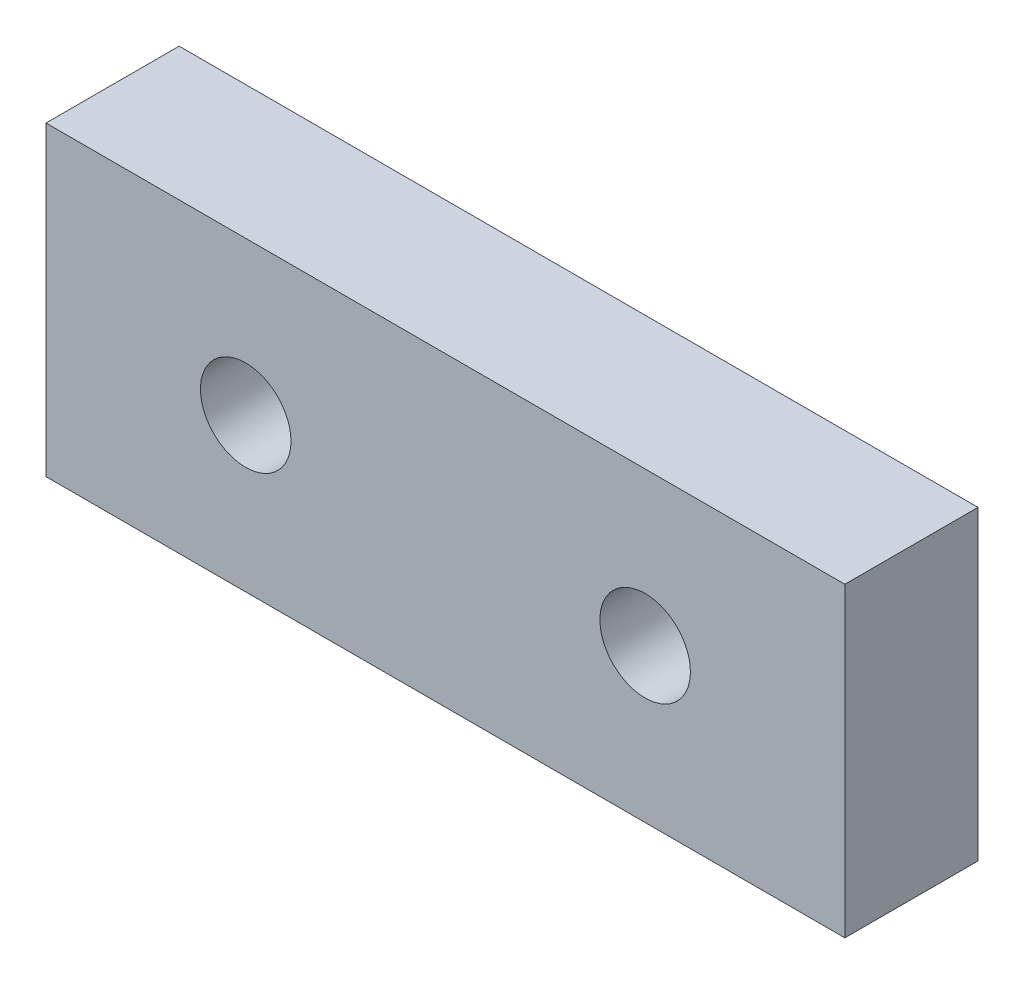
from build123d import *

# Parameters (mm, degrees)
SKETCH1_W            = 30
SKETCH1_H            = 11.5
BOSS_EXTRUDE1_DEPTH  = 5
M3_CLEARANCE_HOLE1_D = 3.4


with BuildPart() as part:
    # Sketch1 → Boss-Extrude1 (new body)
    with BuildSketch(Plane.XY):
        Rectangle(SKETCH1_W, SKETCH1_H)
    extrude(amount=BOSS_EXTRUDE1_DEPTH)

    # M3 Clearance Hole1 (through all)
    with Locations(Plane.XY.offset(5)):
        with Locations((7.5, 0), (-7.5, 0)):
            Hole(M3_CLEARANCE_HOLE1_D / 2)


solid = part.part
